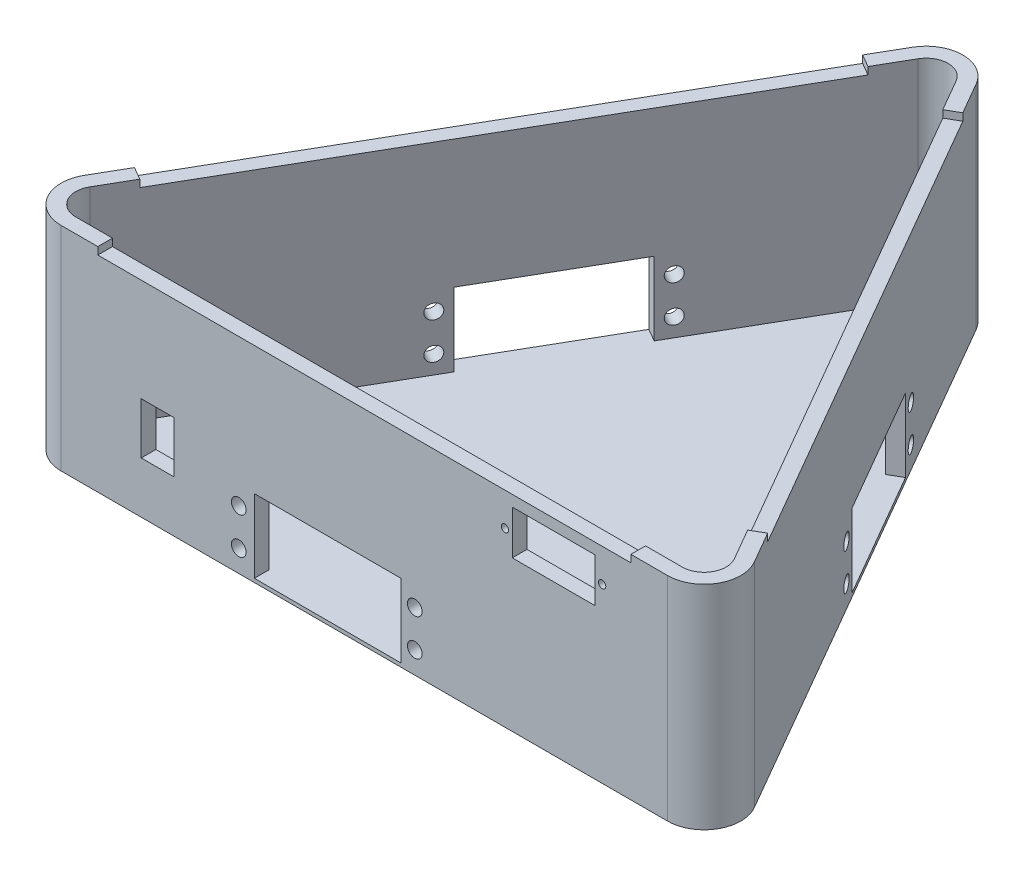
from build123d import *

# Parameters (mm, degrees)
BOSS_EXTRUDE1_DEPTH = 1
BOSS_EXTRUDE2_DEPTH = 55
BOSS_EXTRUDE3_START = -56
BOSS_EXTRUDE3_DEPTH = 58
SKETCH3_R           = 2
SKETCH3_R_2         = 1
SKETCH3_W           = 40
SKETCH3_H           = 20
SKETCH3_W_2         = 22.5
SKETCH3_H_2         = 12
SKETCH3_W_3         = 9
SKETCH3_H_3         = 14
BACK_DEPTH          = 10
SKETCH6_R           = 2
SKETCH6_W           = 40
SKETCH6_H           = 20
CUT_EXTRUDE3_DEPTH  = 10
SKETCH7_R           = 2
SKETCH7_W           = 40
SKETCH7_H           = 20
CUT_EXTRUDE4_DEPTH  = 10
CIRPATTERN1_COUNT   = 3


with BuildPart() as part:
    # Sketch2 → Boss-Extrude1 (new body)
    with BuildSketch(Plane(origin=(0, 0, 0), x_dir=(1, 0, 0), z_dir=(0, 1, 0))):
        with BuildLine():
            Line((-8.660254038, 100.470053838), (-91.339745962, -42.735026919))
            ThreePointArc((-91.339745962, -42.735026919), (-91.339745962, -52.735026919), (-82.679491924, -57.735026919))
            Line((-82.679491924, -57.735026919), (82.679491924, -57.735026919))
            ThreePointArc((82.679491924, -57.735026919), (91.339745962, -52.735026919), (91.339745962, -42.735026919))
            Line((91.339745962, -42.735026919), (8.660254038, 100.470053838))
            ThreePointArc((8.660254038, 100.470053838), (0, 105.470053838), (-8.660254038, 100.470053838))
        make_face()
    extrude(amount=-BOSS_EXTRUDE1_DEPTH)

    # Sketch2_6 → Boss-Extrude2 (add)
    with BuildSketch(Plane(origin=(0, 0, 0), x_dir=(1, 0, 0), z_dir=(0, 1, 0))):
        with BuildLine():
            Line((-8.660254038, 100.470053838), (-91.339745962, -42.735026919))
            ThreePointArc((-91.339745962, -42.735026919), (-91.339745962, -52.735026919), (-82.679491924, -57.735026919))
            Line((-82.679491924, -57.735026919), (82.679491924, -57.735026919))
            ThreePointArc((82.679491924, -57.735026919), (91.339745962, -52.735026919), (91.339745962, -42.735026919))
            Line((91.339745962, -42.735026919), (8.660254038, 100.470053838))
            ThreePointArc((8.660254038, 100.470053838), (0, 105.470053838), (-8.660254038, 100.470053838))
        make_face()
        with BuildLine():
            Line((-5.196152423, 98.470053838), (-87.875644347, -44.735026919))
            ThreePointArc((-87.875644347, -44.735026919), (-87.875644347, -50.735026919), (-82.679491924, -53.735026919))
            Line((-82.679491924, -53.735026919), (82.679491924, -53.735026919))
            ThreePointArc((82.679491924, -53.735026919), (87.875644347, -50.735026919), (87.875644347, -44.735026919))
            Line((87.875644347, -44.735026919), (5.196152423, 98.470053838))
            ThreePointArc((5.196152423, 98.470053838), (0, 101.470053838), (-5.196152423, 98.470053838))
        make_face(mode=Mode.SUBTRACT)
    extrude(amount=BOSS_EXTRUDE2_DEPTH)

    # Sketch4 → Boss-Extrude3 (add)
    with BuildSketch(Plane(origin=(0, 55, 0), x_dir=(1, 0, 0), z_dir=(0, 1, 0)).offset(BOSS_EXTRUDE3_START)):
        with BuildLine():
            Line((0, 105.470053838), (0, 101.470053838))
            ThreePointArc((0, 101.470053838), (-3, 100.666206261), (-5.196152423, 98.470053838))
            Line((-5.196152423, 98.470053838), (-10.196152423, 89.8097998))
            Line((-10.196152423, 89.8097998), (-13.660254038, 91.8097998))
            Line((-13.660254038, 91.8097998), (-8.660254038, 100.470053838))
            ThreePointArc((-8.660254038, 100.470053838), (-5, 104.130307876), (0, 105.470053838))
        make_face()
        with BuildLine():
            Line((-82.875644347, -36.074772881), (-86.339745962, -34.074772881))
            Line((-86.339745962, -34.074772881), (-91.339745962, -42.735026919))
            ThreePointArc((-91.339745962, -42.735026919), (-92.679491924, -47.735026919), (-91.339745962, -52.735026919))
            Line((-91.339745962, -52.735026919), (-87.875644347, -50.735026919))
            ThreePointArc((-87.875644347, -50.735026919), (-88.679491924, -47.735026919), (-87.875644347, -44.735026919))
            Line((-87.875644347, -44.735026919), (-82.875644347, -36.074772881))
        make_face()
    boss_extrude3 = extrude(amount=BOSS_EXTRUDE3_DEPTH)

    # Sketch3 → Back (cut)
    with BuildSketch(Plane.XY.offset(57.735026919)):
        with Locations((-34.24280037, 15)):
            Circle(SKETCH3_R)
        with Locations((-34.24280037, 5)):
            Circle(SKETCH3_R)
        with Locations((13.75719963, 15)):
            Circle(SKETCH3_R)
        with Locations((13.75719963, 5)):
            Circle(SKETCH3_R)
        with Locations((38.339745962, 46)):
            Circle(SKETCH3_R_2)
        with Locations((64.839745962, 46)):
            Circle(SKETCH3_R_2)
        with Locations((-10, 10)):
            Rectangle(SKETCH3_W, SKETCH3_H)
        with Locations((51.589745962, 46)):
            Rectangle(SKETCH3_W_2, SKETCH3_H_2)
        with Locations((-56.339745962, 20)):
            Rectangle(SKETCH3_W_3, SKETCH3_H_3)
    extrude(amount=-BACK_DEPTH, mode=Mode.SUBTRACT)

    # Sketch6 → Cut-Extrude3 (cut)
    with BuildSketch(Plane(origin=(50, 0, -28.867513459), x_dir=(-0.5, 0, -0.866025404), z_dir=(0.866025404, 0, -0.5))):
        with Locations((-14, 15)):
            Circle(SKETCH6_R)
        with Locations((-14, 5)):
            Circle(SKETCH6_R)
        with Locations((34, 15)):
            Circle(SKETCH6_R)
        with Locations((34, 5)):
            Circle(SKETCH6_R)
        with Locations((10, 10)):
            Rectangle(SKETCH6_W, SKETCH6_H)
    extrude(amount=-CUT_EXTRUDE3_DEPTH, mode=Mode.SUBTRACT)

    # Sketch7 → Cut-Extrude4 (cut)
    with BuildSketch(Plane(origin=(-50, 0, -28.867513459), x_dir=(-0.5, 0, 0.866025404), z_dir=(-0.866025404, 0, -0.5))):
        with Locations((-34, 15)):
            Circle(SKETCH7_R)
        with Locations((-34, 5)):
            Circle(SKETCH7_R)
        with Locations((14, 15)):
            Circle(SKETCH7_R)
        with Locations((14, 5)):
            Circle(SKETCH7_R)
        with Locations((-10, 10)):
            Rectangle(SKETCH7_W, SKETCH7_H)
    extrude(amount=-CUT_EXTRUDE4_DEPTH, mode=Mode.SUBTRACT)

    # CirPattern1: Boss-Extrude3 ×3 about axis
    cirpattern1_axis = Axis((0, 0, 0), (0, 1, 0))
    for i in range(1, CIRPATTERN1_COUNT):
        add(boss_extrude3.rotate(cirpattern1_axis, i * 360 / CIRPATTERN1_COUNT))


solid = part.part
